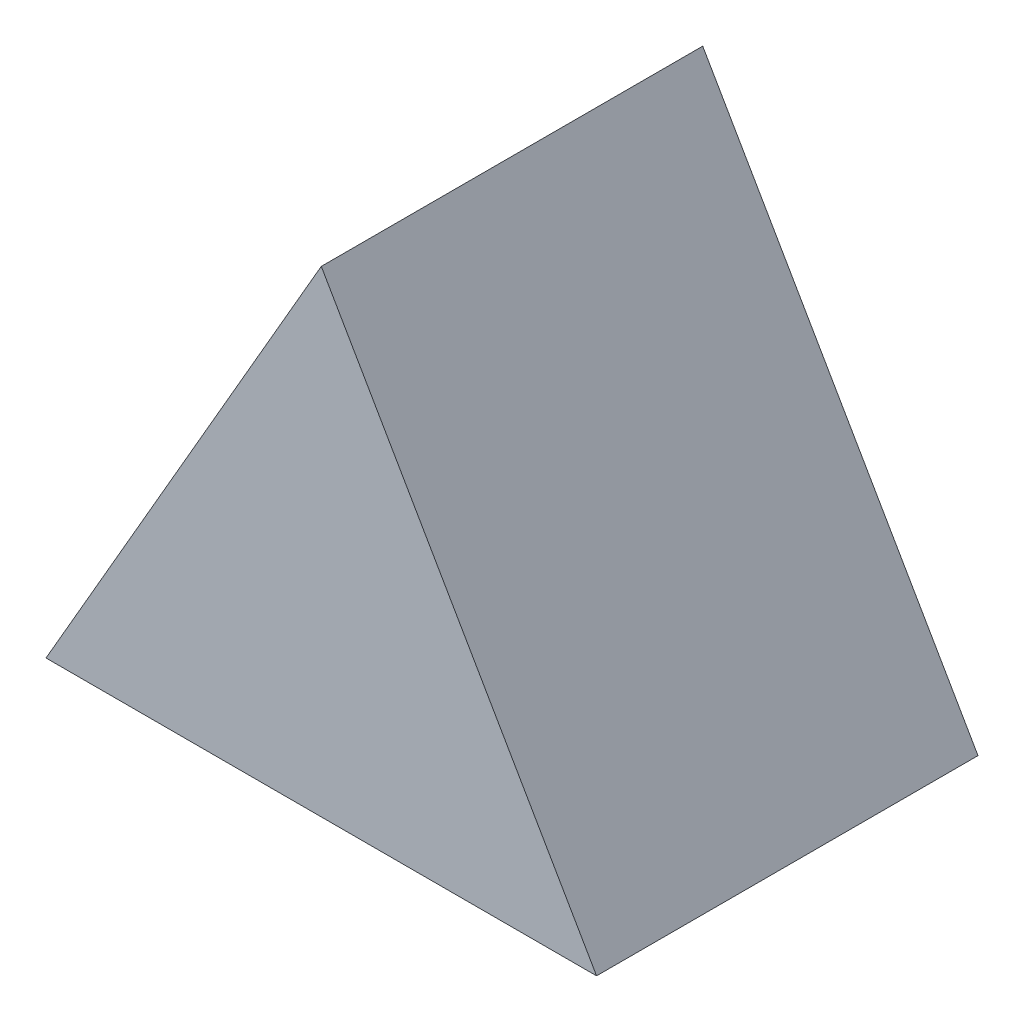
from build123d import *

# Parameters (mm, degrees)
ESTRUSIONE_ESTRUSIONE1_DEPTH = 30


with BuildPart() as part:
    # Schizzo1 → Estrusione-Estrusione1 (new body)
    with BuildSketch(Plane.XY):
        Polygon((0, 25), (-21.650635095, -12.5), (21.650635095, -12.5), align=None)
    extrude(amount=ESTRUSIONE_ESTRUSIONE1_DEPTH)


solid = part.part
